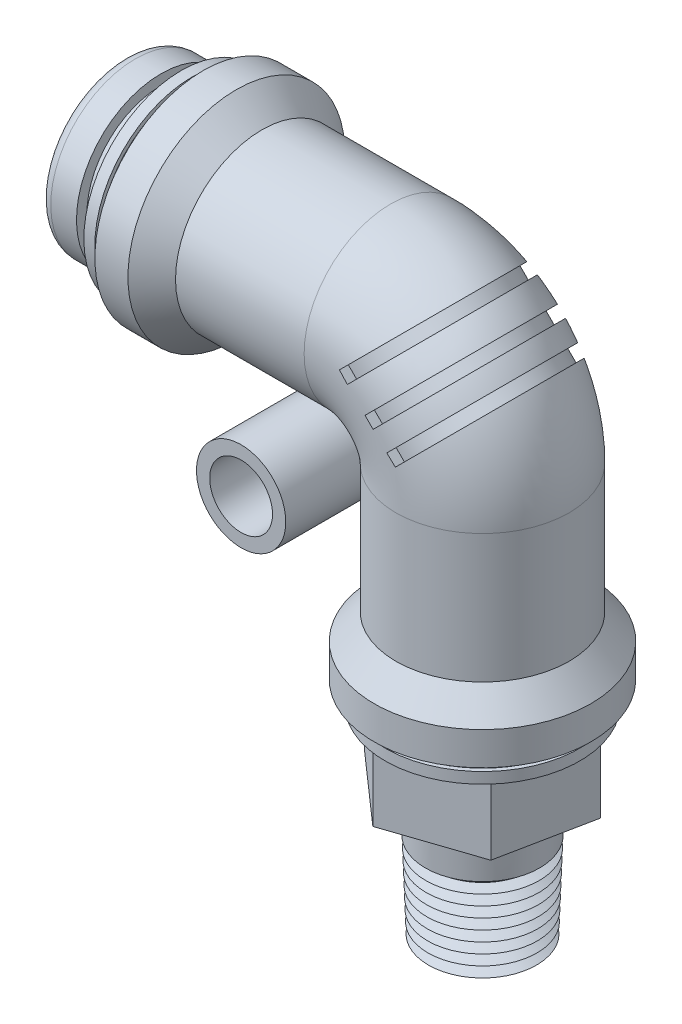
from build123d import *

# Parameters (mm, degrees)
SKETCH11_R                 = 5.9817
SKETCH11_R_2               = 5.08
STRUCTURAL_MEMBER1_DEPTH   = 8.89
SKETCH11_ON_SEGMENT_2_R    = 5.9817
SKETCH11_ON_SEGMENT_2_R_2  = 5.08
STRUCTURAL_MEMBER1_2_ANGLE = 90
SKETCH11_ON_SEGMENT_3_R    = 5.9817
SKETCH11_ON_SEGMENT_3_R_2  = 5.08
STRUCTURAL_MEMBER1_3_DEPTH = 8.89
SKETCH24_R                 = 5.08
EXTRUDE4_DEPTH             = 11.7602
SKETCH25_R                 = 5.08
EXTRUDE5_DEPTH             = 9.2202
SKETCH26_R                 = 3.0861
SKETCH26_R_2               = 2.1717
EXTRUDE6_DEPTH             = 8.5344
EXTRUDE1_DEPTH             = 0.39624
EXTRUDE7_DEPTH             = 0.4064
EXTRUDE8_DEPTH             = 0.8128
EXTRUDE9_DEPTH             = 4.7625
SKETCH32_R                 = 4.0513
EXTRUDE10_DEPTH            = 9.3726
EXTRUDE10_TAPER            = 2
SKETCH33_R                 = 1.7145
EXTRUDE11_DEPTH            = 16.9926


with BuildPart() as part:
    # Sketch11 → Structural Member1 (new body)
    with BuildSketch(Plane.YZ.offset(-15.24)):
        Circle(SKETCH11_R)
        Circle(SKETCH11_R_2, mode=Mode.SUBTRACT)
    extrude(amount=STRUCTURAL_MEMBER1_DEPTH)


with BuildPart() as body_2:
    # Sketch11 on segment 2 (carried to the start of arc 2) → Structural Member1 2 (revolve)
    with BuildSketch(Plane(origin=(0, -6.35, 0), x_dir=(-1, 0, 0), z_dir=(0, 1, 0))):
        Circle(SKETCH11_ON_SEGMENT_2_R)
        Circle(SKETCH11_ON_SEGMENT_2_R_2, mode=Mode.SUBTRACT)
    revolve(axis=Axis((-6.35, -6.35, 0), (0, 0, 1)), revolution_arc=STRUCTURAL_MEMBER1_2_ANGLE)

    # Sketch16 → Extrude1 (cut, symmetric)
    with BuildSketch(Plane(origin=(0, 0, 0), x_dir=(0, 0, -1), z_dir=(0.707106781186548, -0.707106781186547, -3.491483361109382e-15))):
        with BuildLine():
            Line((-6.35, -2.630256121), (-5.334, -2.630256121))
            ThreePointArc((-5.334, -2.630256121), (0, 2.703743879), (5.334, -2.630256121))
            Line((5.334, -2.630256121), (6.35, -2.630256121))
            ThreePointArc((6.35, -2.630256121), (0, 3.719743879), (-6.35, -2.630256121))
        make_face()
    extrude(amount=EXTRUDE1_DEPTH, both=True, mode=Mode.SUBTRACT)

    # Sketch27 → Extrude7 (cut, symmetric)
    with BuildSketch(Plane(origin=(-1.796051224, 1.796051224, 0), x_dir=(0, 0, -1), z_dir=(0.707106781186548, -0.7071067811865471, -3.4914833611093825e-15))):
        with BuildLine():
            Line((-5.334, -2.630256121), (-6.35, -2.630256121))
            ThreePointArc((-6.35, -2.630256121), (0, 3.719743879), (6.35, -2.630256121))
            Line((6.35, -2.630256121), (5.334, -2.630256121))
            ThreePointArc((5.334, -2.630256121), (0, 2.703743879), (-5.334, -2.630256121))
        make_face()
    extrude(amount=EXTRUDE7_DEPTH, both=True, mode=Mode.SUBTRACT)

    # Sketch28 → Extrude8 (cut)
    with BuildSketch(Plane(origin=(1.796051224, -1.796051224, 0), x_dir=(0, 0, -1), z_dir=(0.707106781186548, -0.7071067811865471, -3.4914833611093825e-15))):
        with BuildLine():
            Line((-6.35, -2.630256121), (-5.334, -2.630256121))
            ThreePointArc((-5.334, -2.630256121), (0, 2.703743879), (5.334, -2.630256121))
            Line((5.334, -2.630256121), (6.35, -2.630256121))
            ThreePointArc((6.35, -2.630256121), (0, 3.719743879), (-6.35, -2.630256121))
        make_face()
    extrude(amount=-EXTRUDE8_DEPTH, mode=Mode.SUBTRACT)


with BuildPart() as body_3:
    # Sketch11 on segment 3 (carried to segment 3) → Structural Member1 3 (new body)
    with BuildSketch(Plane.XZ.offset(6.35)):
        Circle(SKETCH11_ON_SEGMENT_3_R)
        Circle(SKETCH11_ON_SEGMENT_3_R_2, mode=Mode.SUBTRACT)
    extrude(amount=STRUCTURAL_MEMBER1_3_DEPTH)


with BuildPart() as body_4:
    # Sketch21 → Revolve1 (revolve)
    with BuildSketch(Plane.XY):
        Polygon((-15.24, 0), (-20.828, 0), (-20.828, 6.731), (-20.066, 6.731), (-20.066, 6.4516), (-19.304, 6.4516), (-19.304, 7.493), (-17.018, 7.493), (-15.24, 5.9817), align=None)
    revolve(axis=Axis((-15.24, 0, 0), (-1, 0, 0)))

    # Sketch24 → Extrude4 (cut)
    with BuildSketch(Plane.ZY.offset(20.828)):
        with Locations(Location((0, 0, 0), (0, 0, 270))):
            Circle(SKETCH24_R)
    extrude(amount=-EXTRUDE4_DEPTH, mode=Mode.SUBTRACT)


with BuildPart() as body_5:
    # Sketch23 → Revolve2 (revolve)
    with BuildSketch(Plane.XY):
        Polygon((0, -15.24), (0, -20.828), (-6.731, -20.828), (-6.731, -20.066), (-6.4516, -20.066), (-6.4516, -19.304), (-7.493, -19.304), (-7.493, -17.018), (-5.9817, -15.24), align=None)
    revolve(axis=Axis((0, -15.24, 0), (0, -1, 0)))

    # Sketch25 → Extrude5 (cut)
    with BuildSketch(Plane.XZ.offset(20.828)):
        Circle(SKETCH25_R)
    extrude(amount=-EXTRUDE5_DEPTH, mode=Mode.SUBTRACT)


with BuildPart() as body_6:
    # Sketch26 → Extrude6 (new, symmetric)
    with BuildSketch(Plane.XY):
        with Locations((-8.1534, -8.1534)):
            Circle(SKETCH26_R)
        with Locations((-8.1534, -8.1534)):
            Circle(SKETCH26_R_2, mode=Mode.SUBTRACT)
    extrude(amount=EXTRUDE6_DEPTH, both=True)


with BuildPart() as body_7:
    # Sketch30 → Revolve3 (revolve)
    with BuildSketch(Plane.XY):
        with BuildLine():
            Line((-24.765, 3.175), (-24.765, 5.08))
            ThreePointArc((-24.765, 5.08), (-24.541815367, 5.618815367), (-24.003, 5.842))
            Line((-24.003, 5.842), (-22.225, 5.842))
            Line((-22.225, 5.842), (-22.225, 5.126581495))
            Line((-22.225, 5.126581495), (-20.828, 5.08))
            Line((-20.828, 5.08), (-20.828, 3.175))
            Line((-20.828, 3.175), (-24.765, 3.175))
        make_face()
    revolve(axis=Axis((-20.828, 0, 0), (-1, 0, 0)))


with BuildPart() as body_8:
    # Sketch31 → Extrude9 (new body)
    with BuildSketch(Plane.XZ.offset(20.828)):
        Polygon((1.270178463, -6.311255036), (6.100796422, -2.055620701), (4.830617959, 4.255634335), (-1.270178463, 6.311255036), (-6.100796422, 2.055620701), (-4.830617959, -4.255634335), align=None)
    extrude(amount=EXTRUDE9_DEPTH)


with BuildPart() as body_9:
    # Sketch32 → Extrude10 (new body)
    with BuildSketch(Plane.XZ.offset(25.5905)):
        Circle(SKETCH32_R)
    extrude(amount=EXTRUDE10_DEPTH, taper=EXTRUDE10_TAPER)


with BuildPart() as extrude11_tool:
    # Sketch33 → Extrude11 (new body)
    with BuildSketch(Plane.XZ.offset(34.9631)):
        Circle(SKETCH33_R)
    extrude(amount=-EXTRUDE11_DEPTH)


with BuildPart() as body_8_1:
    add(body_8.part)

    # Extrude11: cut by extrude11_tool
    add(extrude11_tool.part, mode=Mode.SUBTRACT)


with BuildPart() as body_9_1:
    add(body_9.part)

    # Extrude11: cut by extrude11_tool
    add(extrude11_tool.part, mode=Mode.SUBTRACT)

    # Sketch34 → Cut-Revolve1 (revolve, cut)
    with BuildSketch(Plane.XY, mode=Mode.PRIVATE) as cut_revolve1_sk:
        Polygon((-3.088614535, -34.9631), (-3.738606797, -34.544861765), (-3.114441116, -34.223523485), (-3.764433378, -33.80528525), (-3.141946608, -33.435869265), (-3.790040829, -33.071983781), (-3.167359767, -32.708131608), (-3.815660452, -32.338333784), (-3.192686859, -31.982858583), (-3.841304592, -31.603981684), (-3.217558335, -31.270632682), (-3.867051191, -30.866695556), (-3.243079806, -30.539793369), (-3.892838499, -30.128243689), (-3.270989121, -29.740575178), (-3.918428063, -29.39545444), (-3.291780903, -29.145176439), (-4.333993902, -28.324192464), (-4.333993902, -34.9631), align=None)
    revolve(cut_revolve1_sk.sketch.rotate(Axis((0, -25.886343082, 0), (0, -1, 0)), 270), axis=Axis((0, -25.886343082, 0), (0, -1, 0)), mode=Mode.SUBTRACT)


solid = Compound([part.part, body_2.part, body_3.part, body_4.part, body_5.part, body_6.part, body_7.part, body_8_1.part, body_9_1.part])
